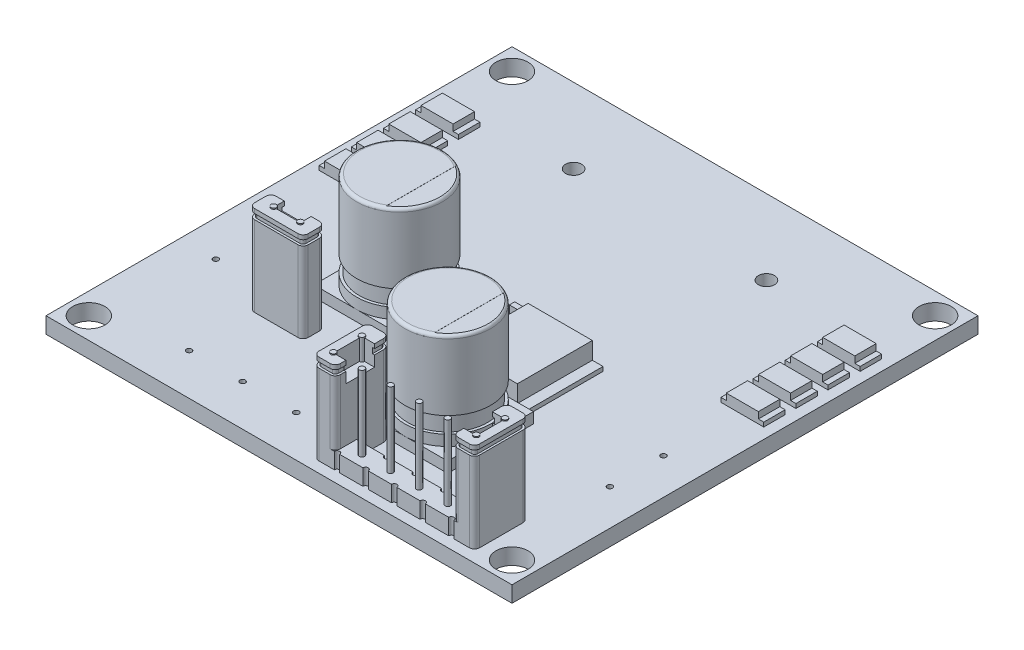
from build123d import *

# Parameters (mm, degrees)
IZIM1_W                                  = 43.5
IZIM1_H                                  = 43.5
IZIM1_R                                  = 1.5
Y_KSEKLIK_EKSTR_ZYON1_DEPTH              = 1.5
IZIM2_R                                  = 0.75
KES_EKSTR_ZYON1_DEPTH                    = 10
IZIM3_W                                  = 8
IZIM3_H                                  = 8
Y_KSEKLIK_EKSTR_ZYON2_DEPTH              = 1
IZIM4_R                                  = 4
Y_KSEKLIK_EKSTR_ZYON3_DEPTH              = 1
IZIM5_R                                  = 3.75
Y_KSEKLIK_EKSTR_ZYON4_DEPTH              = 1.5
IZIM6_R                                  = 4
Y_KSEKLIK_EKSTR_ZYON5_DEPTH              = 6.5
RADYUS1_R                                = 0.3
KES_EKSTR_ZYON2_DEPTH                    = 0.01
IZIM8_R                                  = 0.25
Y_KSEKLIK_EKSTR_ZYON6_DEPTH              = 1.5
IZIM9_R                                  = 0.25
KES_EKSTR_ZYON3_DEPTH                    = 5
IZIM10_R                                 = 0.25
Y_KSEKLIK_EKSTR_ZYON7_DEPTH              = 7
Y_KSEKLIK_EKSTR_ZYON7_DEPTH_BACK         = 3.5
IZIM11_R                                 = 0.25
Y_KSEKLIK_EKSTR_ZYON8_DEPTH              = 5
Y_KSEKLIK_EKSTR_ZYON10_DEPTH             = 1
Y_KSEKLIK_EKSTR_ZYON11_DEPTH             = 0.5
Y_KSEKLIK_EKSTR_ZYON12_DEPTH             = 0.4
IZIM15_R                                 = 0.25
KES_EKSTR_ZYON4_DEPTH                    = 5
IZIM16_R                                 = 0.25
KES_EKSTR_ZYON5_DEPTH                    = 7
IZIM18_W                                 = 3
IZIM18_H                                 = 2
Y_KSEKLIK_EKSTR_ZYON13_DEPTH             = 1
IZIM19_W                                 = 0.5
IZIM19_H                                 = 2
Y_KSEKLIK_EKSTR_ZYON14_DEPTH             = 0.4
IZIM20_W                                 = 6
IZIM20_H                                 = 7
Y_KSEKLIK_EKSTR_ZYON15_DEPTH             = 2
IZIM21_W                                 = 1
IZIM21_H                                 = 7
Y_KSEKLIK_EKSTR_ZYON16_DEPTH             = 0.4
IZIM22_W                                 = 1.25
IZIM22_H                                 = 1
IZIM22_H_2                               = 0.5
Y_KSEKLIK_EKSTR_ZYON17_DEPTH             = 1.5
IZIM23_R                                 = 0.25
Y_KSEKLIK_EKSTR_ZYON18_DEPTH             = 7.5
Y_KSEKLIK_EKSTR_ZYON19_REACH             = 12
IZIM24_R                                 = 0.25
Y_KSEKLIK_EKSTR_ZYON19_DIRECTION_2_REACH = 4
Y_KSEKLIK_EKSTR_ZYON20_DEPTH             = 0.5
Y_KSEKLIK_EKSTR_ZYON21_DEPTH             = 0.4


with BuildPart() as part:
    # Çizim1 → Yükseklik-Ekstrüzyon1 (new body)
    with BuildSketch(Plane(origin=(0, 0, 0), x_dir=(1, 0, 0), z_dir=(0, 1, 0))):
        Rectangle(IZIM1_W, IZIM1_H)
        with Locations((-19.75, 19.75)):
            Circle(IZIM1_R, mode=Mode.SUBTRACT)
        with Locations((19.75, 19.75)):
            Circle(IZIM1_R, mode=Mode.SUBTRACT)
        with Locations((19.75, -19.75)):
            Circle(IZIM1_R, mode=Mode.SUBTRACT)
        with Locations((-19.75, -19.75)):
            Circle(IZIM1_R, mode=Mode.SUBTRACT)
    extrude(amount=Y_KSEKLIK_EKSTR_ZYON1_DEPTH)

    # Çizim2 → Kes-Ekstrüzyon1 (cut)
    with BuildSketch(Plane(origin=(0, 1.5, 0), x_dir=(1, 0, 0), z_dir=(0, 1, 0))):
        with Locations((-9, 14.75)):
            Circle(IZIM2_R)
        with Locations((9, 14.75)):
            Circle(IZIM2_R)
    extrude(amount=-KES_EKSTR_ZYON1_DEPTH, mode=Mode.SUBTRACT)

    # Çizim3 → Yükseklik-Ekstrüzyon2 (add)
    with BuildSketch(Plane(origin=(0, 1.5, 0), x_dir=(1, 0, 0), z_dir=(0, 1, 0))):
        with Locations((-6.75, -3.75)):
            Rectangle(IZIM3_W, IZIM3_H)
        with Locations((5.75, -11.75)):
            Rectangle(IZIM3_W, IZIM3_H)
    extrude(amount=Y_KSEKLIK_EKSTR_ZYON2_DEPTH)

    # Çizim4 → Yükseklik-Ekstrüzyon3 (add)
    with BuildSketch(Plane(origin=(0, 2.5, 0), x_dir=(1, 0, 0), z_dir=(0, 1, 0))):
        with Locations((-6.75, -3.75)):
            Circle(IZIM4_R)
        with Locations((5.75, -11.75)):
            Circle(IZIM4_R)
    extrude(amount=Y_KSEKLIK_EKSTR_ZYON3_DEPTH)

    # Çizim5 → Yükseklik-Ekstrüzyon4 (add)
    with BuildSketch(Plane(origin=(0, 3.5, 0), x_dir=(1, 0, 0), z_dir=(0, 1, 0))):
        with Locations((-6.75, -3.75)):
            Circle(IZIM5_R)
        with Locations((5.75, -11.75)):
            Circle(IZIM5_R)
    extrude(amount=Y_KSEKLIK_EKSTR_ZYON4_DEPTH)

    # Çizim6 → Yükseklik-Ekstrüzyon5 (add)
    with BuildSketch(Plane(origin=(0, 5, 0), x_dir=(1, 0, 0), z_dir=(0, 1, 0))):
        with Locations((-6.75, -3.75)):
            Circle(IZIM6_R)
        with Locations((5.75, -11.75)):
            Circle(IZIM6_R)
    extrude(amount=Y_KSEKLIK_EKSTR_ZYON5_DEPTH)

    # Radyus1
    radyus1_edges = [part.edges().sort_by_distance(p)[0] for p in [
        (1.75, 11.5, 11.75),
        (-10.75, 11.5, 3.75),
    ]]
    fillet(radyus1_edges, radius=RADYUS1_R)

    # Çizim7 → Kes-Ekstrüzyon2 (cut)
    with BuildSketch(Plane(origin=(0, 11.5, 0), x_dir=(1, 0, 0), z_dir=(0, 1, 0))):
        with BuildLine():
            Line((-4.74980323, -0.286011998), (-4.74980323, -7.213988002))
            ThreePointArc((-4.74980323, -7.213988002), (-2.75, -3.75), (-4.74980323, -0.286011998))
        make_face()
        with BuildLine():
            Line((7.75, -8.285898385), (7.75, -15.214101615))
            ThreePointArc((7.75, -15.214101615), (9.75, -11.75), (7.75, -8.285898385))
        make_face()
    extrude(amount=-KES_EKSTR_ZYON2_DEPTH, mode=Mode.SUBTRACT)

    # Çizim8 → Yükseklik-Ekstrüzyon6 (add)
    with BuildSketch(Plane(origin=(0, 1.5, 0), x_dir=(1, 0, 0), z_dir=(0, 1, 0))):
        with BuildLine():
            Line((4.25, -18.75), (6.833333333, -18.75))
            ThreePointArc((6.833333333, -18.75), (7.083333333, -19), (7.333333333, -18.75))
            Line((7.333333333, -18.75), (9.5, -18.75))
            ThreePointArc((9.5, -18.75), (9.75, -19), (10, -18.75))
            Line((10, -18.75), (12.166666667, -18.75))
            ThreePointArc((12.166666667, -18.75), (12.416666667, -19), (12.666666667, -18.75))
            Line((12.666666667, -18.75), (15.25, -18.75))
            Line((15.25, -18.75), (15.25, -16.226499645))
            ThreePointArc((15.25, -16.226499645), (15.389563515, -15.889563515), (15.726499645, -15.75))
            Line((15.726499645, -15.75), (16.773500355, -15.75))
            ThreePointArc((16.773500355, -15.75), (17.110436485, -15.889563515), (17.25, -16.226499645))
            Line((17.25, -16.226499645), (17.25, -20.273500355))
            ThreePointArc((17.25, -20.273500355), (17.110436485, -20.610436485), (16.773500355, -20.75))
            Line((16.773500355, -20.75), (15.333333333, -20.75))
            ThreePointArc((15.333333333, -20.75), (15.083333333, -20.5), (14.833333333, -20.75))
            Line((14.833333333, -20.75), (12.666666667, -20.75))
            ThreePointArc((12.666666667, -20.75), (12.416666667, -20.5), (12.166666667, -20.75))
            Line((12.166666667, -20.75), (10, -20.75))
            ThreePointArc((10, -20.75), (9.75, -20.5), (9.5, -20.75))
            Line((9.5, -20.75), (7.333333333, -20.75))
            ThreePointArc((7.333333333, -20.75), (7.083333333, -20.5), (6.833333333, -20.75))
            Line((6.833333333, -20.75), (4.666666667, -20.75))
            ThreePointArc((4.666666667, -20.75), (4.416666667, -20.5), (4.166666667, -20.75))
            Line((4.166666667, -20.75), (2.726499645, -20.75))
            ThreePointArc((2.726499645, -20.75), (2.389563515, -20.610436485), (2.25, -20.273500355))
            Line((2.25, -20.273500355), (2.25, -16.226499645))
            ThreePointArc((2.25, -16.226499645), (2.389563515, -15.889563515), (2.726499645, -15.75))
            Line((2.726499645, -15.75), (3.773500355, -15.75))
            ThreePointArc((3.773500355, -15.75), (4.110436485, -15.889563515), (4.25, -16.226499645))
            Line((4.25, -16.226499645), (4.25, -18.75))
        make_face()
        with Locations((11.085, -19.75)):
            Circle(IZIM8_R, mode=Mode.SUBTRACT)
        with Locations((13.755, -19.75)):
            Circle(IZIM8_R, mode=Mode.SUBTRACT)
        with Locations((16.425, -19.75)):
            Circle(IZIM8_R, mode=Mode.SUBTRACT)
        with Locations((16.425, -17.08)):
            Circle(IZIM8_R, mode=Mode.SUBTRACT)
        with Locations((3.075, -17.08)):
            Circle(IZIM8_R, mode=Mode.SUBTRACT)
        with Locations((3.075, -19.75)):
            Circle(IZIM8_R, mode=Mode.SUBTRACT)
        with Locations((5.745, -19.75)):
            Circle(IZIM8_R, mode=Mode.SUBTRACT)
        with Locations((8.415, -19.75)):
            Circle(IZIM8_R, mode=Mode.SUBTRACT)
    extrude(amount=Y_KSEKLIK_EKSTR_ZYON6_DEPTH)

    # Çizim9 → Kes-Ekstrüzyon3 (cut)
    with BuildSketch(Plane(origin=(0, 3, 0), x_dir=(1, 0, 0), z_dir=(0, 1, 0))):
        with Locations((3.075, -17.08)):
            Circle(IZIM9_R)
        with Locations((3.075, -19.75)):
            Circle(IZIM9_R)
        with Locations((5.745, -19.75)):
            Circle(IZIM9_R)
        with Locations((8.415, -19.75)):
            Circle(IZIM9_R)
        with Locations((11.085, -19.75)):
            Circle(IZIM9_R)
        with Locations((13.755, -19.75)):
            Circle(IZIM9_R)
        with Locations((16.425, -19.75)):
            Circle(IZIM9_R)
        with Locations((16.425, -17.08)):
            Circle(IZIM9_R)
    extrude(amount=-KES_EKSTR_ZYON3_DEPTH, mode=Mode.SUBTRACT)

    # Çizim10 → Yükseklik-Ekstrüzyon7 (add, two sides)
    with BuildSketch(Plane(origin=(0, 3, 0), x_dir=(1, 0, 0), z_dir=(0, 1, 0))) as y_kseklik_ekstr_zyon7_sk:
        with Locations((3.075, -17.08)):
            Circle(IZIM10_R)
        with Locations((3.075, -19.75)):
            Circle(IZIM10_R)
        with Locations((5.745, -19.75)):
            Circle(IZIM10_R)
        with Locations((8.415, -19.75)):
            Circle(IZIM10_R)
        with Locations((11.085, -19.75)):
            Circle(IZIM10_R)
        with Locations((13.755, -19.75)):
            Circle(IZIM10_R)
        with Locations((16.425, -19.75)):
            Circle(IZIM10_R)
        with Locations((16.425, -17.08)):
            Circle(IZIM10_R)
    extrude(amount=Y_KSEKLIK_EKSTR_ZYON7_DEPTH)
    extrude(y_kseklik_ekstr_zyon7_sk.sketch, amount=-Y_KSEKLIK_EKSTR_ZYON7_DEPTH_BACK)

    # Çizim11 → Yükseklik-Ekstrüzyon8 (add)
    with BuildSketch(Plane(origin=(0, 3, 0), x_dir=(1, 0, 0), z_dir=(0, 1, 0))):
        with BuildLine():
            Line((16.773500355, -20.75), (15.726499645, -20.75))
            ThreePointArc((15.726499645, -20.75), (15.389563515, -20.610436485), (15.25, -20.273500355))
            Line((15.25, -20.273500355), (15.25, -16.226499645))
            ThreePointArc((15.25, -16.226499645), (15.389563515, -15.889563515), (15.726499645, -15.75))
            Line((15.726499645, -15.75), (16.773500355, -15.75))
            ThreePointArc((16.773500355, -15.75), (17.110436485, -15.889563515), (17.25, -16.226499645))
            Line((17.25, -16.226499645), (17.25, -20.273500355))
            ThreePointArc((17.25, -20.273500355), (17.110436485, -20.610436485), (16.773500355, -20.75))
        make_face()
        with Locations((16.425, -19.75)):
            Circle(IZIM11_R, mode=Mode.SUBTRACT)
        with Locations((16.425, -17.08)):
            Circle(IZIM11_R, mode=Mode.SUBTRACT)
        with BuildLine():
            Line((2.726499645, -15.75), (3.773500355, -15.75))
            ThreePointArc((3.773500355, -15.75), (4.110436485, -15.889563515), (4.25, -16.226499645))
            Line((4.25, -16.226499645), (4.25, -20.273500355))
            ThreePointArc((4.25, -20.273500355), (4.110436485, -20.610436485), (3.773500355, -20.75))
            Line((3.773500355, -20.75), (2.726499645, -20.75))
            ThreePointArc((2.726499645, -20.75), (2.389563515, -20.610436485), (2.25, -20.273500355))
            Line((2.25, -20.273500355), (2.25, -16.226499645))
            ThreePointArc((2.25, -16.226499645), (2.389563515, -15.889563515), (2.726499645, -15.75))
        make_face()
        with Locations((3.075, -17.08)):
            Circle(IZIM11_R, mode=Mode.SUBTRACT)
        with Locations((3.075, -19.75)):
            Circle(IZIM11_R, mode=Mode.SUBTRACT)
    extrude(amount=Y_KSEKLIK_EKSTR_ZYON8_DEPTH)

    # Çizim12 → Yükseklik-Ekstrüzyon10 (add)
    with BuildSketch(Plane(origin=(0, 8, 0), x_dir=(1, 0, 0), z_dir=(0, 1, 0))):
        with BuildLine():
            Line((3.325, -17.08), (4.25, -17.08))
            Line((4.25, -17.08), (4.25, -16.226499645))
            ThreePointArc((4.25, -16.226499645), (4.110436485, -15.889563515), (3.773500355, -15.75))
            Line((3.773500355, -15.75), (2.726499645, -15.75))
            ThreePointArc((2.726499645, -15.75), (2.389563515, -15.889563515), (2.25, -16.226499645))
            Line((2.25, -16.226499645), (2.25, -20.273500355))
            ThreePointArc((2.25, -20.273500355), (2.389563515, -20.610436485), (2.726499645, -20.75))
            Line((2.726499645, -20.75), (3.773500355, -20.75))
            ThreePointArc((3.773500355, -20.75), (4.110436485, -20.610436485), (4.25, -20.273500355))
            Line((4.25, -20.273500355), (4.25, -19.75))
            Line((4.25, -19.75), (3.325, -19.75))
            ThreePointArc((3.325, -19.75), (2.898223305, -19.926776695), (3.075, -19.5))
            Line((3.075, -19.5), (3.075, -17.33))
            ThreePointArc((3.075, -17.33), (2.898223305, -16.903223305), (3.325, -17.08))
        make_face()
        with BuildLine():
            Line((16.175, -17.08), (15.25, -17.08))
            Line((15.25, -17.08), (15.25, -16.226499645))
            ThreePointArc((15.25, -16.226499645), (15.389563515, -15.889563515), (15.726499645, -15.75))
            Line((15.726499645, -15.75), (16.773500355, -15.75))
            ThreePointArc((16.773500355, -15.75), (17.110436485, -15.889563515), (17.25, -16.226499645))
            Line((17.25, -16.226499645), (17.25, -20.273500355))
            ThreePointArc((17.25, -20.273500355), (17.110436485, -20.610436485), (16.773500355, -20.75))
            Line((16.773500355, -20.75), (15.726499645, -20.75))
            ThreePointArc((15.726499645, -20.75), (15.389563515, -20.610436485), (15.25, -20.273500355))
            Line((15.25, -20.273500355), (15.25, -19.75))
            Line((15.25, -19.75), (16.175, -19.75))
            ThreePointArc((16.175, -19.75), (16.601776695, -19.926776695), (16.425, -19.5))
            Line((16.425, -19.5), (16.425, -17.33))
            ThreePointArc((16.425, -17.33), (16.601776695, -16.903223305), (16.175, -17.08))
        make_face()
    extrude(amount=Y_KSEKLIK_EKSTR_ZYON10_DEPTH)

    # Çizim13 → Yükseklik-Ekstrüzyon11 (add)
    with BuildSketch(Plane(origin=(0, 9, 0), x_dir=(1, 0, 0), z_dir=(0, 1, 0))):
        with BuildLine():
            Line((3.075, -17.33), (3.075, -19.5))
            ThreePointArc((3.075, -19.5), (2.898223305, -19.926776695), (3.325, -19.75))
            Line((3.325, -19.75), (4.061841211, -19.75))
            Line((4.061841211, -19.75), (4.061841211, -20.266506285))
            ThreePointArc((4.061841211, -20.266506285), (3.98085634, -20.462021059), (3.785341566, -20.54300593))
            Line((3.785341566, -20.54300593), (2.714658434, -20.54300593))
            ThreePointArc((2.714658434, -20.54300593), (2.51914366, -20.462021059), (2.438158789, -20.266506285))
            Line((2.438158789, -20.266506285), (2.438158789, -16.233493715))
            ThreePointArc((2.438158789, -16.233493715), (2.51914366, -16.037978941), (2.714658434, -15.95699407))
            Line((2.714658434, -15.95699407), (3.785341566, -15.95699407))
            ThreePointArc((3.785341566, -15.95699407), (3.98085634, -16.037978941), (4.061841211, -16.233493715))
            Line((4.061841211, -16.233493715), (4.061841211, -17.08))
            Line((4.061841211, -17.08), (3.325, -17.08))
            ThreePointArc((3.325, -17.08), (2.898223305, -16.903223305), (3.075, -17.33))
        make_face()
        with BuildLine():
            Line((16.785341566, -15.95699407), (15.714658434, -15.95699407))
            ThreePointArc((15.714658434, -15.95699407), (15.51914366, -16.037978941), (15.438158789, -16.233493715))
            Line((15.438158789, -16.233493715), (15.438158789, -17.08))
            Line((15.438158789, -17.08), (16.175, -17.08))
            ThreePointArc((16.175, -17.08), (16.601776695, -16.903223305), (16.425, -17.33))
            Line((16.425, -17.33), (16.425, -19.5))
            ThreePointArc((16.425, -19.5), (16.601776695, -19.926776695), (16.175, -19.75))
            Line((16.175, -19.75), (15.438158789, -19.75))
            Line((15.438158789, -19.75), (15.438158789, -20.266506285))
            ThreePointArc((15.438158789, -20.266506285), (15.51914366, -20.462021059), (15.714658434, -20.54300593))
            Line((15.714658434, -20.54300593), (16.785341566, -20.54300593))
            ThreePointArc((16.785341566, -20.54300593), (16.98085634, -20.462021059), (17.061841211, -20.266506285))
            Line((17.061841211, -20.266506285), (17.061841211, -16.233493715))
            ThreePointArc((17.061841211, -16.233493715), (16.98085634, -16.037978941), (16.785341566, -15.95699407))
        make_face()
    extrude(amount=Y_KSEKLIK_EKSTR_ZYON11_DEPTH)

    # Çizim14 → Yükseklik-Ekstrüzyon12 (add)
    with BuildSketch(Plane(origin=(0, 9.5, 0), x_dir=(1, 0, 0), z_dir=(0, 1, 0))):
        with BuildLine():
            Line((4.25, -17.08), (3.325, -17.08))
            ThreePointArc((3.325, -17.08), (2.898223305, -16.903223305), (3.075, -17.33))
            Line((3.075, -17.33), (3.075, -19.5))
            ThreePointArc((3.075, -19.5), (2.898223305, -19.926776695), (3.325, -19.75))
            Line((3.325, -19.75), (4.25, -19.75))
            Line((4.25, -19.75), (4.25, -20.273500355))
            ThreePointArc((4.25, -20.273500355), (4.110436485, -20.610436485), (3.773500355, -20.75))
            Line((3.773500355, -20.75), (2.726499645, -20.75))
            ThreePointArc((2.726499645, -20.75), (2.389563515, -20.610436485), (2.25, -20.273500355))
            Line((2.25, -20.273500355), (2.25, -16.226499645))
            ThreePointArc((2.25, -16.226499645), (2.389563515, -15.889563515), (2.726499645, -15.75))
            Line((2.726499645, -15.75), (3.773500355, -15.75))
            ThreePointArc((3.773500355, -15.75), (4.110436485, -15.889563515), (4.25, -16.226499645))
            Line((4.25, -16.226499645), (4.25, -17.08))
        make_face()
        with BuildLine():
            Line((15.25, -17.08), (16.175, -17.08))
            ThreePointArc((16.175, -17.08), (16.601776695, -16.903223305), (16.425, -17.33))
            Line((16.425, -17.33), (16.425, -19.5))
            ThreePointArc((16.425, -19.5), (16.601776695, -19.926776695), (16.175, -19.75))
            Line((16.175, -19.75), (15.25, -19.75))
            Line((15.25, -19.75), (15.25, -20.273500355))
            ThreePointArc((15.25, -20.273500355), (15.389563515, -20.610436485), (15.726499645, -20.75))
            Line((15.726499645, -20.75), (16.773500355, -20.75))
            ThreePointArc((16.773500355, -20.75), (17.110436485, -20.610436485), (17.25, -20.273500355))
            Line((17.25, -20.273500355), (17.25, -16.226499645))
            ThreePointArc((17.25, -16.226499645), (17.110436485, -15.889563515), (16.773500355, -15.75))
            Line((16.773500355, -15.75), (15.726499645, -15.75))
            ThreePointArc((15.726499645, -15.75), (15.389563515, -15.889563515), (15.25, -16.226499645))
            Line((15.25, -16.226499645), (15.25, -17.08))
        make_face()
    extrude(amount=Y_KSEKLIK_EKSTR_ZYON12_DEPTH)

    # Çizim15 → Kes-Ekstrüzyon4 (cut)
    with BuildSketch(Plane(origin=(0, 1.5, 0), x_dir=(1, 0, 0), z_dir=(0, 1, 0))):
        with Locations((-12.25, -17.89)):
            Circle(IZIM15_R)
        with Locations((-7.25, -17.89)):
            Circle(IZIM15_R)
        with Locations((-2.25, -17.89)):
            Circle(IZIM15_R)
    extrude(amount=-KES_EKSTR_ZYON4_DEPTH, mode=Mode.SUBTRACT)

    # Çizim16 → Kes-Ekstrüzyon5 (cut)
    with BuildSketch(Plane(origin=(0, 1.5, 0), x_dir=(1, 0, 0), z_dir=(0, 1, 0))):
        with Locations((18.39, -4.25)):
            Circle(IZIM16_R)
        with Locations((18.39, -9.25)):
            Circle(IZIM16_R)
        with Locations((-18.39, -9.25)):
            Circle(IZIM16_R)
        with Locations((-18.39, -4.25)):
            Circle(IZIM16_R)
    extrude(amount=-KES_EKSTR_ZYON5_DEPTH, mode=Mode.SUBTRACT)

    # Çizim18 → Yükseklik-Ekstrüzyon13 (add)
    with BuildSketch(Plane(origin=(0, 1.5, 0), x_dir=(1, 0, 0), z_dir=(0, 1, 0))):
        with Locations((18.75, 12.75)):
            Rectangle(IZIM18_W, IZIM18_H)
        with Locations((18.75, 9.75)):
            Rectangle(IZIM18_W, IZIM18_H)
        with Locations((18.75, 6.75)):
            Rectangle(IZIM18_W, IZIM18_H)
        with Locations((18.75, 3.75)):
            Rectangle(IZIM18_W, IZIM18_H)
        with Locations((-18.75, 3.75)):
            Rectangle(IZIM18_W, IZIM18_H)
        with Locations((-18.75, 6.75)):
            Rectangle(IZIM18_W, IZIM18_H)
        with Locations((-18.75, 9.75)):
            Rectangle(IZIM18_W, IZIM18_H)
        with Locations((-18.75, 12.75)):
            Rectangle(IZIM18_W, IZIM18_H)
    extrude(amount=Y_KSEKLIK_EKSTR_ZYON13_DEPTH)

    # Çizim19 → Yükseklik-Ekstrüzyon14 (add)
    with BuildSketch(Plane(origin=(0, 1.5, 0), x_dir=(1, 0, 0), z_dir=(0, 1, 0))):
        with Locations((17, 12.75)):
            Rectangle(IZIM19_W, IZIM19_H)
        with Locations((20.5, 12.75)):
            Rectangle(IZIM19_W, IZIM19_H)
        with Locations((20.5, 9.75)):
            Rectangle(IZIM19_W, IZIM19_H)
        with Locations((17, 9.75)):
            Rectangle(IZIM19_W, IZIM19_H)
        with Locations((20.5, 6.75)):
            Rectangle(IZIM19_W, IZIM19_H)
        with Locations((17, 6.75)):
            Rectangle(IZIM19_W, IZIM19_H)
        with Locations((20.5, 3.75)):
            Rectangle(IZIM19_W, IZIM19_H)
        with Locations((17, 3.75)):
            Rectangle(IZIM19_W, IZIM19_H)
        with Locations((-20.5, 3.75)):
            Rectangle(IZIM19_W, IZIM19_H)
        with Locations((-17, 3.75)):
            Rectangle(IZIM19_W, IZIM19_H)
        with Locations((-20.5, 6.75)):
            Rectangle(IZIM19_W, IZIM19_H)
        with Locations((-17, 6.75)):
            Rectangle(IZIM19_W, IZIM19_H)
        with Locations((-17, 9.75)):
            Rectangle(IZIM19_W, IZIM19_H)
        with Locations((-20.5, 9.75)):
            Rectangle(IZIM19_W, IZIM19_H)
        with Locations((-20.5, 12.75)):
            Rectangle(IZIM19_W, IZIM19_H)
        with Locations((-17, 12.75)):
            Rectangle(IZIM19_W, IZIM19_H)
    extrude(amount=Y_KSEKLIK_EKSTR_ZYON14_DEPTH)

    # Çizim20 → Yükseklik-Ekstrüzyon15 (add)
    with BuildSketch(Plane(origin=(0, 1.5, 0), x_dir=(1, 0, 0), z_dir=(0, 1, 0))):
        with Locations((4.75, -3.75)):
            Rectangle(IZIM20_W, IZIM20_H)
    extrude(amount=Y_KSEKLIK_EKSTR_ZYON15_DEPTH)

    # Çizim21 → Yükseklik-Ekstrüzyon16 (add)
    with BuildSketch(Plane(origin=(0, 1.5, 0), x_dir=(1, 0, 0), z_dir=(0, 1, 0))):
        with Locations((8.25, -3.75)):
            Rectangle(IZIM21_W, IZIM21_H)
    extrude(amount=Y_KSEKLIK_EKSTR_ZYON16_DEPTH)

    # Çizim22 → Yükseklik-Ekstrüzyon17 (add)
    with BuildSketch(Plane(origin=(0, 1.5, 0), x_dir=(1, 0, 0), z_dir=(0, 1, 0))):
        with Locations((1.125, -3.75)):
            Rectangle(IZIM22_W, IZIM22_H)
        with Locations((1.125, -7)):
            Rectangle(IZIM22_W, IZIM22_H_2)
        with Locations((1.125, -0.5)):
            Rectangle(IZIM22_W, IZIM22_H_2)
    extrude(amount=Y_KSEKLIK_EKSTR_ZYON17_DEPTH)

    # Çizim23 → Yükseklik-Ekstrüzyon18 (add)
    with BuildSketch(Plane(origin=(0, 1.5, 0), x_dir=(1, 0, 0), z_dir=(0, 1, 0))):
        with BuildLine():
            Line((-12.273500355, -11.75), (-8.226499645, -11.75))
            ThreePointArc((-8.226499645, -11.75), (-7.889563515, -11.610436485), (-7.75, -11.273500355))
            Line((-7.75, -11.273500355), (-7.75, -10.226499645))
            ThreePointArc((-7.75, -10.226499645), (-7.889563515, -9.889563515), (-8.226499645, -9.75))
            Line((-8.226499645, -9.75), (-12.273500355, -9.75))
            ThreePointArc((-12.273500355, -9.75), (-12.610436485, -9.889563515), (-12.75, -10.226499645))
            Line((-12.75, -10.226499645), (-12.75, -11.273500355))
            ThreePointArc((-12.75, -11.273500355), (-12.610436485, -11.610436485), (-12.273500355, -11.75))
        make_face()
        with Locations((-11.5, -10.75)):
            Circle(IZIM23_R, mode=Mode.SUBTRACT)
        with Locations((-9, -10.75)):
            Circle(IZIM23_R, mode=Mode.SUBTRACT)
    extrude(amount=Y_KSEKLIK_EKSTR_ZYON18_DEPTH)

    # Yükseklik-Ekstrüzyon19: up to this face of the body (flat: up to its plane)
    y_kseklik_ekstr_zyon19_end = Plane(part.part.faces().sort_by_distance((11.085, 10, 19.75))[0])
    # Çizim24 → Yükseklik-Ekstrüzyon19 (add, up to the picked face)
    with BuildSketch(Plane(origin=(0, 1.5, 0), x_dir=(1, 0, 0), z_dir=(0, 1, 0)), mode=Mode.PRIVATE) as y_kseklik_ekstr_zyon19_sk1:
        with Locations((-11.5, -10.75)):
            Circle(IZIM24_R)
    y_kseklik_ekstr_zyon19_tool1 = split(extrude(y_kseklik_ekstr_zyon19_sk1.sketch, amount=Y_KSEKLIK_EKSTR_ZYON19_REACH, mode=Mode.PRIVATE), bisect_by=y_kseklik_ekstr_zyon19_end, keep=Keep.BOTH, mode=Mode.PRIVATE)
    add(y_kseklik_ekstr_zyon19_tool1.solids().sort_by_distance((-11.5, 1.5, 10.75))[0])
    # Çizim24 → Yükseklik-Ekstrüzyon19 (add, up to the picked face)
    with BuildSketch(Plane(origin=(0, 1.5, 0), x_dir=(1, 0, 0), z_dir=(0, 1, 0)), mode=Mode.PRIVATE) as y_kseklik_ekstr_zyon19_sk2:
        with Locations((-9, -10.75)):
            Circle(IZIM24_R)
    y_kseklik_ekstr_zyon19_tool2 = split(extrude(y_kseklik_ekstr_zyon19_sk2.sketch, amount=Y_KSEKLIK_EKSTR_ZYON19_REACH, mode=Mode.PRIVATE), bisect_by=y_kseklik_ekstr_zyon19_end, keep=Keep.BOTH, mode=Mode.PRIVATE)
    add(y_kseklik_ekstr_zyon19_tool2.solids().sort_by_distance((-9, 1.5, 10.75))[0])

    # Yükseklik-Ekstrüzyon19 direction 2: up to this face of the body (flat: up to its plane)
    y_kseklik_ekstr_zyon19_direction_2_end = Plane(part.part.faces().sort_by_distance((3.075, -0.5, 17.08))[0])
    # Çizim24 → Yükseklik-Ekstrüzyon19 direction 2 (add, up to the picked face)
    with BuildSketch(Plane(origin=(0, 1.5, 0), x_dir=(1, 0, 0), z_dir=(0, 1, 0)), mode=Mode.PRIVATE) as y_kseklik_ekstr_zyon19_direction_2_sk1:
        with Locations((-11.5, -10.75)):
            Circle(IZIM24_R)
    y_kseklik_ekstr_zyon19_direction_2_tool1 = split(extrude(y_kseklik_ekstr_zyon19_direction_2_sk1.sketch, amount=-Y_KSEKLIK_EKSTR_ZYON19_DIRECTION_2_REACH, mode=Mode.PRIVATE), bisect_by=y_kseklik_ekstr_zyon19_direction_2_end, keep=Keep.BOTH, mode=Mode.PRIVATE)
    add(y_kseklik_ekstr_zyon19_direction_2_tool1.solids().sort_by_distance((-11.5, 1.5, 10.75))[0])
    # Çizim24 → Yükseklik-Ekstrüzyon19 direction 2 (add, up to the picked face)
    with BuildSketch(Plane(origin=(0, 1.5, 0), x_dir=(1, 0, 0), z_dir=(0, 1, 0)), mode=Mode.PRIVATE) as y_kseklik_ekstr_zyon19_direction_2_sk2:
        with Locations((-9, -10.75)):
            Circle(IZIM24_R)
    y_kseklik_ekstr_zyon19_direction_2_tool2 = split(extrude(y_kseklik_ekstr_zyon19_direction_2_sk2.sketch, amount=-Y_KSEKLIK_EKSTR_ZYON19_DIRECTION_2_REACH, mode=Mode.PRIVATE), bisect_by=y_kseklik_ekstr_zyon19_direction_2_end, keep=Keep.BOTH, mode=Mode.PRIVATE)
    add(y_kseklik_ekstr_zyon19_direction_2_tool2.solids().sort_by_distance((-9, 1.5, 10.75))[0])

    # Çizim25 → Yükseklik-Ekstrüzyon20 (add)
    with BuildSketch(Plane(origin=(0, 9, 0), x_dir=(1, 0, 0), z_dir=(0, 1, 0))):
        with BuildLine():
            Line((-12.55, -10.226499645), (-12.55, -11.273500355))
            ThreePointArc((-12.55, -11.273500355), (-12.469015129, -11.469015129), (-12.273500355, -11.55))
            Line((-12.273500355, -11.55), (-8.226499645, -11.55))
            ThreePointArc((-8.226499645, -11.55), (-8.030984871, -11.469015129), (-7.95, -11.273500355))
            Line((-7.95, -11.273500355), (-7.95, -10.226499645))
            ThreePointArc((-7.95, -10.226499645), (-8.030984871, -10.030984871), (-8.226499645, -9.95))
            Line((-8.226499645, -9.95), (-9, -9.95))
            Line((-9, -9.95), (-9, -10.5))
            ThreePointArc((-9, -10.5), (-8.823223305, -10.926776695), (-9.25, -10.75))
            Line((-9.25, -10.75), (-11.25, -10.75))
            ThreePointArc((-11.25, -10.75), (-11.676776695, -10.926776695), (-11.5, -10.5))
            Line((-11.5, -10.5), (-11.5, -9.95))
            Line((-11.5, -9.95), (-12.273500355, -9.95))
            ThreePointArc((-12.273500355, -9.95), (-12.469015129, -10.030984871), (-12.55, -10.226499645))
        make_face()
    extrude(amount=Y_KSEKLIK_EKSTR_ZYON20_DEPTH)

    # Çizim27 → Yükseklik-Ekstrüzyon21 (add)
    with BuildSketch(Plane(origin=(0, 9.5, 0), x_dir=(1, 0, 0), z_dir=(0, 1, 0))):
        with BuildLine():
            Line((-11.5, -9.75), (-11.5, -10.5))
            ThreePointArc((-11.5, -10.5), (-11.676776695, -10.926776695), (-11.25, -10.75))
            Line((-11.25, -10.75), (-9.25, -10.75))
            ThreePointArc((-9.25, -10.75), (-8.823223305, -10.926776695), (-9, -10.5))
            Line((-9, -10.5), (-9, -9.75))
            Line((-9, -9.75), (-8.226499645, -9.75))
            ThreePointArc((-8.226499645, -9.75), (-7.889563515, -9.889563515), (-7.75, -10.226499645))
            Line((-7.75, -10.226499645), (-7.75, -11.273500355))
            ThreePointArc((-7.75, -11.273500355), (-7.889563515, -11.610436485), (-8.226499645, -11.75))
            Line((-8.226499645, -11.75), (-12.273500355, -11.75))
            ThreePointArc((-12.273500355, -11.75), (-12.610436485, -11.610436485), (-12.75, -11.273500355))
            Line((-12.75, -11.273500355), (-12.75, -10.226499645))
            ThreePointArc((-12.75, -10.226499645), (-12.610436485, -9.889563515), (-12.273500355, -9.75))
            Line((-12.273500355, -9.75), (-11.5, -9.75))
        make_face()
    extrude(amount=Y_KSEKLIK_EKSTR_ZYON21_DEPTH)


solid = part.part
